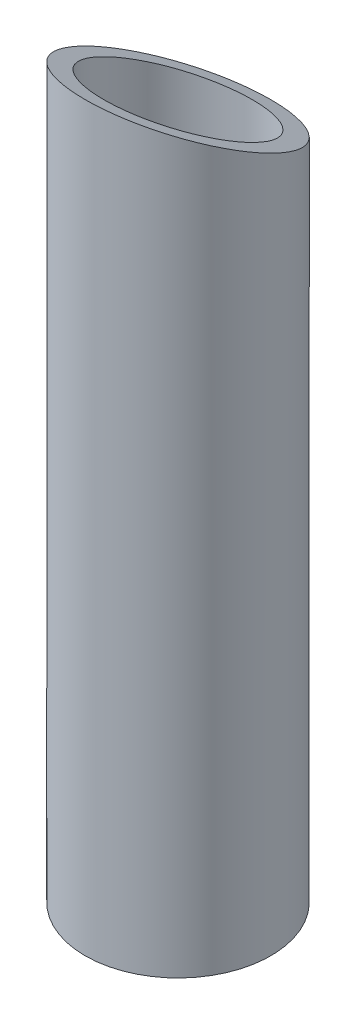
from build123d import *

# Parameters (mm, degrees)
SKETCH1_R               = 15.9
SKETCH1_R_2             = 12.725
BOSS_EXTRUDE1_DEPTH     = 127
CUT_EXTRUDE1_DEPTH      = 16.9
CUT_EXTRUDE1_DEPTH_BACK = 16.9


with BuildPart() as part:
    # Sketch1 → Boss-Extrude1 (new body)
    with BuildSketch(Plane(origin=(0, 0, 0), x_dir=(1, 0, 0), z_dir=(0, 1, 0))):
        Circle(SKETCH1_R)
        Circle(SKETCH1_R_2, mode=Mode.SUBTRACT)
    extrude(amount=BOSS_EXTRUDE1_DEPTH)

    # Sketch2 → Cut-Extrude1 (cut, two sides)
    with BuildSketch(Plane(origin=(0, 0, 0), x_dir=(0, 0, -1), z_dir=(1, 0, 0))) as cut_extrude1_sk:
        Polygon((15.9, 127), (-15.9, 127), (15.9, 111.1), align=None)
    extrude(amount=CUT_EXTRUDE1_DEPTH, mode=Mode.SUBTRACT)
    extrude(cut_extrude1_sk.sketch, amount=-CUT_EXTRUDE1_DEPTH_BACK, mode=Mode.SUBTRACT)


solid = part.part
